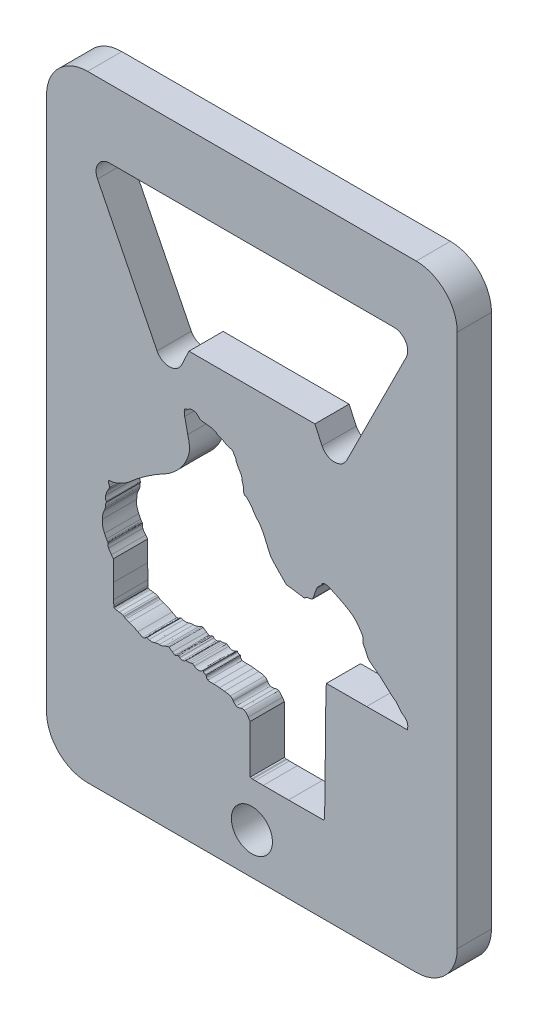
from build123d import *

# Parameters (mm, degrees)
BOSS_EXTRUDE1_DEPTH = 3.175
SKETCH3_R           = 1.905
CUT_EXTRUDE1_DEPTH  = 4.175
CUT_EXTRUDE3_DEPTH  = 4.175


with BuildPart() as part:
    # Sketch1 → Boss-Extrude1 (new body)
    with BuildSketch(Plane.XY):
        with BuildLine():
            Line((40.64, 0), (10.16, 0))
            ThreePointArc((10.16, 0), (7.465923164, 1.115923164), (6.35, 3.81))
            Line((6.35, 3.81), (6.35, 53.34))
            ThreePointArc((6.35, 53.34), (7.465923164, 56.034076836), (10.16, 57.15))
            Line((10.16, 57.15), (40.64, 57.15))
            ThreePointArc((40.64, 57.15), (43.334076836, 56.034076836), (44.45, 53.34))
            Line((44.45, 53.34), (44.45, 3.81))
            ThreePointArc((44.45, 3.81), (43.334076836, 1.115923164), (40.64, 0))
        make_face()
        with BuildLine():
            Line((38.585096834, 50.8), (12.214903166, 50.8))
            ThreePointArc((12.214903166, 50.8), (11.134576639, 50.197678512), (11.078980633, 48.962038734))
            Line((11.078980633, 48.962038734), (16.604643113, 37.910713774))
            ThreePointArc((16.604643113, 37.910713774), (17.757723109, 37.208790943), (18.891418233, 37.9416105))
            Line((18.891418233, 37.9416105), (19.558, 39.37))
            Line((19.558, 39.37), (31.242, 39.37))
            Line((31.242, 39.37), (31.908581767, 37.9416105))
            ThreePointArc((31.908581767, 37.9416105), (33.042276891, 37.208790943), (34.195356887, 37.910713774))
            Line((34.195356887, 37.910713774), (39.721019367, 48.962038734))
            ThreePointArc((39.721019367, 48.962038734), (39.665423361, 50.197678512), (38.585096834, 50.8))
        make_face(mode=Mode.SUBTRACT)
    extrude(amount=BOSS_EXTRUDE1_DEPTH)

    # Sketch3 → Cut-Extrude1 (cut, through all)
    with BuildSketch(Plane.XY.offset(3.175)):
        with Locations((25.4, 3.81)):
            Circle(SKETCH3_R)
    extrude(amount=-CUT_EXTRUDE1_DEPTH, mode=Mode.SUBTRACT)

    # Sketch4 → Cut-Extrude3 (cut, through all)
    with BuildSketch(Plane.XY.offset(3.175)):
        with BuildLine():
            Line((25.059420308, 12.72168685), (25.240760339, 12.460211785))
            Line((25.240760339, 12.460211785), (25.240760339, 10.238510318))
            Line((25.240760339, 10.238510318), (25.240760339, 7.985427565))
            Line((25.240760339, 7.985427565), (25.391840027, 7.948779703))
            add(Edge.make_bspline(
                [(25.391840027, 7.948779703), (25.401896377, 7.946340795), (25.410802303, 7.945881683), (25.426808204, 7.944854678)],
                knots=[0, 0, 0, 0, 1, 1, 1, 1], degree=3))
            add(Edge.make_bspline(
                [(25.426808204, 7.944854678), (25.442814105, 7.94382808), (25.464036361, 7.942967194), (25.490243788, 7.942054866)],
                knots=[0, 0, 0, 0, 1, 1, 1, 1], degree=3))
            add(Edge.make_bspline(
                [(25.490243788, 7.942054866), (25.542658439, 7.940223093), (25.615230725, 7.93847875), (25.705991628, 7.937009713)],
                knots=[0, 0, 0, 0, 1, 1, 1, 1], degree=3))
            add(Edge.make_bspline(
                [(25.705991628, 7.937009713), (25.887513637, 7.934072247), (26.141472517, 7.931908848), (26.449286212, 7.930509958)],
                knots=[0, 0, 0, 0, 1, 1, 1, 1], degree=3))
            add(Edge.make_bspline(
                [(26.449286212, 7.930509958), (27.064919499, 7.927716449), (27.896186357, 7.928169868), (28.794613545, 7.932536722)],
                knots=[0, 0, 0, 0, 1, 1, 1, 1], degree=3))
            Line((28.794613545, 7.932536722), (32.083175645, 7.948449093))
            Line((32.083175645, 7.948449093), (32.129799746, 8.122616968))
            add(Edge.make_bspline(
                [(32.129799746, 8.122616968), (32.133133699, 8.135083353), (32.133540963, 8.146493048), (32.135067542, 8.168568463)],
                knots=[0, 0, 0, 0, 1, 1, 1, 1], degree=3))
            add(Edge.make_bspline(
                [(32.135067542, 8.168568463), (32.136593917, 8.190643269), (32.138085728, 8.220487199), (32.139663952, 8.257781234)],
                knots=[0, 0, 0, 0, 1, 1, 1, 1], degree=3))
            add(Edge.make_bspline(
                [(32.139663952, 8.257781234), (32.1428143, 8.332369914), (32.146166553, 8.436970066), (32.149526938, 8.568346961)],
                knots=[0, 0, 0, 0, 1, 1, 1, 1], degree=3))
            add(Edge.make_bspline(
                [(32.149526938, 8.568346961), (32.156247099, 8.831099326), (32.163293802, 9.200897461), (32.170260599, 9.650786101)],
                knots=[0, 0, 0, 0, 1, 1, 1, 1], degree=3))
            add(Edge.make_bspline(
                [(32.170260599, 9.650786101), (32.184195615, 10.550562364), (32.197803681, 11.770447913), (32.207694726, 13.09345319)],
                knots=[0, 0, 0, 0, 1, 1, 1, 1], degree=3))
            add(Edge.make_bspline(
                [(32.207694726, 13.09345319), (32.217584755, 14.416347654), (32.230245317, 15.685149613), (32.242774937, 16.66355263)],
                knots=[0, 0, 0, 0, 1, 1, 1, 1], degree=3))
            add(Edge.make_bspline(
                [(32.242774937, 16.66355263), (32.255303946, 17.641955038), (32.267789038, 18.332002957), (32.276731562, 18.490518923)],
                knots=[0, 0, 0, 0, 1, 1, 1, 1], degree=3))
            Line((32.276731562, 18.490518923), (32.308337728, 19.051352127))
            Line((32.308337728, 19.051352127), (36.048793882, 19.066034167))
            Line((36.048793882, 19.066034167), (39.842934666, 19.080828239))
            Line((39.842934666, 19.080828239), (39.860418958, 19.337036525))
            add(Edge.make_bspline(
                [(39.860418958, 19.337036525), (39.880872028, 19.637326715), (39.719870796, 19.908036893), (39.410544551, 20.103306247)],
                knots=[0, 0, 0, 0, 1, 1, 1, 1], degree=3))
            add(Edge.make_bspline(
                [(39.410544551, 20.103306247), (39.294622542, 20.176484448), (39.11265972, 20.36999055), (39.01793882, 20.523930642)],
                knots=[0, 0, 0, 0, 1, 1, 1, 1], degree=3))
            add(Edge.make_bspline(
                [(39.01793882, 20.523930642), (38.915230423, 20.690853163), (38.758066582, 20.858887272), (38.640575701, 20.918666427)],
                knots=[0, 0, 0, 0, 1, 1, 1, 1], degree=3))
            add(Edge.make_bspline(
                [(38.640575701, 20.918666427), (38.59685877, 20.940908774), (38.478925653, 21.031353707), (38.336062817, 21.154139222)],
                knots=[0, 0, 0, 0, 1, 1, 1, 1], degree=3))
            add(Edge.make_bspline(
                [(38.336062817, 21.154139222), (38.19319937, 21.276925347), (38.02165055, 21.433513163), (37.856373148, 21.593705764)],
                knots=[0, 0, 0, 0, 1, 1, 1, 1], degree=3))
            add(Edge.make_bspline(
                [(37.856373148, 21.593705764), (37.523759455, 21.916086822), (37.073205529, 22.296095835), (36.847904574, 22.443024805)],
                knots=[0, 0, 0, 0, 1, 1, 1, 1], degree=3))
            add(Edge.make_bspline(
                [(36.847904574, 22.443024805), (36.362019938, 22.759891839), (36.106825034, 23.030346231), (36.059668013, 23.255133583)],
                knots=[0, 0, 0, 0, 1, 1, 1, 1], degree=3))
            add(Edge.make_bspline(
                [(36.059668013, 23.255133583), (36.036862653, 23.363840127), (35.940892919, 23.566534983), (35.842910655, 23.721038087)],
                knots=[0, 0, 0, 0, 1, 1, 1, 1], degree=3))
            add(Edge.make_bspline(
                [(35.842910655, 23.721038087), (35.770134838, 23.835792186), (35.729311046, 23.912354764), (35.709875425, 23.982289696)],
                knots=[0, 0, 0, 0, 1, 1, 1, 1], degree=3))
            add(Edge.make_bspline(
                [(35.709875425, 23.982289696), (35.6904396, 24.052224018), (35.691016236, 24.117548103), (35.704383766, 24.215073492)],
                knots=[0, 0, 0, 0, 1, 1, 1, 1], degree=3))
            add(Edge.make_bspline(
                [(35.704383766, 24.215073492), (35.719190445, 24.323100517), (35.719703439, 24.40230472), (35.681968591, 24.504119495)],
                knots=[0, 0, 0, 0, 1, 1, 1, 1], degree=3))
            add(Edge.make_bspline(
                [(35.681968591, 24.504119495), (35.644233336, 24.605934677), (35.57059948, 24.730168084), (35.438201071, 24.941443543)],
                knots=[0, 0, 0, 0, 1, 1, 1, 1], degree=3))
            add(Edge.make_bspline(
                [(35.438201071, 24.941443543), (35.02973685, 25.59325399), (34.602306898, 25.925205447), (33.426641514, 26.505702812)],
                knots=[0, 0, 0, 0, 1, 1, 1, 1], degree=3))
            add(Edge.make_bspline(
                [(33.426641514, 26.505702812), (32.691182543, 26.868843411), (32.433813463, 26.970933491), (32.228986926, 26.970933491)],
                knots=[0, 0, 0, 0, 1, 1, 1, 1], degree=3))
            add(Edge.make_bspline(
                [(32.228986926, 26.970933491), (32.123207478, 26.970933491), (32.056047553, 26.96658392), (32.004609075, 26.94302686)],
                knots=[0, 0, 0, 0, 1, 1, 1, 1], degree=3))
            add(Edge.make_bspline(
                [(32.004609075, 26.94302686), (31.953170191, 26.919468784), (31.924363025, 26.875427546), (31.901273821, 26.814699261)],
                knots=[0, 0, 0, 0, 1, 1, 1, 1], degree=3))
            add(Edge.make_bspline(
                [(31.901273821, 26.814699261), (31.889353572, 26.783344407), (31.855332492, 26.732458572), (31.811052141, 26.681438948)],
                knots=[0, 0, 0, 0, 1, 1, 1, 1], degree=3))
            add(Edge.make_bspline(
                [(31.811052141, 26.681438948), (31.766771587, 26.630419934), (31.712161615, 26.577990441), (31.659411881, 26.537756094)],
                knots=[0, 0, 0, 0, 1, 1, 1, 1], degree=3))
            add(Edge.make_bspline(
                [(31.659411881, 26.537756094), (31.560492685, 26.462307137), (31.496088452, 26.397515565), (31.419118812, 26.232010437)],
                knots=[0, 0, 0, 0, 1, 1, 1, 1], degree=3))
            add(Edge.make_bspline(
                [(31.419118812, 26.232010437), (31.342149377, 26.066506326), (31.249330601, 25.798758216), (31.082552036, 25.304685602)],
                knots=[0, 0, 0, 0, 1, 1, 1, 1], degree=3))
            add(Edge.make_bspline(
                [(31.082552036, 25.304685602), (31.054624056, 25.221950219), (31.03663165, 25.184712302), (30.994459393, 25.159433876)],
                knots=[0, 0, 0, 0, 1, 1, 1, 1], degree=3))
            add(Edge.make_bspline(
                [(30.994459393, 25.159433876), (30.952287137, 25.134155857), (30.87642868, 25.119622247), (30.735785971, 25.102050931)],
                knots=[0, 0, 0, 0, 1, 1, 1, 1], degree=3))
            add(Edge.make_bspline(
                [(30.735785971, 25.102050931), (30.528016682, 25.076091359), (30.391868313, 25.029262914), (30.332084482, 24.943910306)],
                knots=[0, 0, 0, 0, 1, 1, 1, 1], degree=3))
            add(Edge.make_bspline(
                [(30.332084482, 24.943910306), (30.312716975, 24.916259054), (30.29190178, 24.894243213), (30.276606303, 24.882604166)],
                knots=[0, 0, 0, 0, 1, 1, 1, 1], degree=3))
            add(Edge.make_bspline(
                [(30.276606303, 24.882604166), (30.26965435, 24.877313394), (30.26462404, 24.875039995), (30.262372803, 24.874197611)],
                knots=[0, 0, 0, 0, 1, 1, 1, 1], degree=3))
            add(Edge.make_bspline(
                [(30.262372803, 24.874197611), (30.260037389, 24.875109939), (30.256530202, 24.87807099), (30.254191128, 24.878903005)],
                knots=[0, 0, 0, 0, 1, 1, 1, 1], degree=3))
            add(Edge.make_bspline(
                [(30.254191128, 24.878903005), (30.249101243, 24.880716275), (30.243391618, 24.882351837), (30.236483176, 24.8841708)],
                knots=[0, 0, 0, 0, 1, 1, 1, 1], degree=3))
            add(Edge.make_bspline(
                [(30.236483176, 24.8841708), (30.222665887, 24.887803237), (30.204273333, 24.891934232), (30.181341301, 24.896610956)],
                knots=[0, 0, 0, 0, 1, 1, 1, 1], degree=3))
            add(Edge.make_bspline(
                [(30.181341301, 24.896610956), (30.135477033, 24.905965015), (30.071667124, 24.917448111), (29.994172697, 24.930458599)],
                knots=[0, 0, 0, 0, 1, 1, 1, 1], degree=3))
            add(Edge.make_bspline(
                [(29.994172697, 24.930458599), (29.839183438, 24.956480795), (29.629578107, 24.988439936), (29.40263305, 25.020008283)],
                knots=[0, 0, 0, 0, 1, 1, 1, 1], degree=3))
            Line((29.40263305, 25.020008283), (28.587945476, 25.133318557))
            Line((28.587945476, 25.133318557), (27.874800016, 25.857896484))
            add(Edge.make_bspline(
                [(27.874800016, 25.857896484), (27.277236399, 26.4650978), (27.136174226, 26.642236283), (27.023349294, 26.924307153)],
                knots=[0, 0, 0, 0, 1, 1, 1, 1], degree=3))
            add(Edge.make_bspline(
                [(27.023349294, 26.924307153), (26.586831438, 28.01563514), (26.257460404, 28.655407612), (25.977110493, 28.942029144)],
                knots=[0, 0, 0, 0, 1, 1, 1, 1], degree=3))
            add(Edge.make_bspline(
                [(25.977110493, 28.942029144), (25.825280935, 29.097255279), (25.625395448, 29.361548863), (25.538105134, 29.521579209)],
                knots=[0, 0, 0, 0, 1, 1, 1, 1], degree=3))
            add(Edge.make_bspline(
                [(25.538105134, 29.521579209), (25.454179475, 29.675440613), (25.301604521, 29.88077506), (25.157380003, 30.049349613)],
                knots=[0, 0, 0, 0, 1, 1, 1, 1], degree=3))
            add(Edge.make_bspline(
                [(25.157380003, 30.049349613), (25.085267439, 30.133635567), (25.015355483, 30.208523748), (24.956761929, 30.263079432)],
                knots=[0, 0, 0, 0, 1, 1, 1, 1], degree=3))
            add(Edge.make_bspline(
                [(24.956761929, 30.263079432), (24.927465354, 30.290357782), (24.901112549, 30.312575324), (24.877859666, 30.32864446)],
                knots=[0, 0, 0, 0, 1, 1, 1, 1], degree=3))
            add(Edge.make_bspline(
                [(24.877859666, 30.32864446), (24.854606784, 30.344714206), (24.836366929, 30.356551701), (24.811398373, 30.356551701)],
                knots=[0, 0, 0, 0, 1, 1, 1, 1], degree=3))
            add(Edge.make_bspline(
                [(24.811398373, 30.356551701), (24.753051454, 30.356551701), (24.705869017, 30.394470153), (24.668724224, 30.477818973)],
                knots=[0, 0, 0, 0, 1, 1, 1, 1], degree=3))
            add(Edge.make_bspline(
                [(24.668724224, 30.477818973), (24.631579837, 30.561168404), (24.609547527, 30.687303325), (24.609547527, 30.84509504)],
                knots=[0, 0, 0, 0, 1, 1, 1, 1], degree=3))
            add(Edge.make_bspline(
                [(24.609547527, 30.84509504), (24.609547527, 30.939053463), (24.603101655, 31.028287584), (24.592399741, 31.097716841)],
                knots=[0, 0, 0, 0, 1, 1, 1, 1], degree=3))
            add(Edge.make_bspline(
                [(24.592399741, 31.097716841), (24.587051631, 31.13243208), (24.580725112, 31.162153201), (24.573122918, 31.185809484)],
                knots=[0, 0, 0, 0, 1, 1, 1, 1], degree=3))
            add(Edge.make_bspline(
                [(24.573122918, 31.185809484), (24.565520115, 31.20946536), (24.560628881, 31.228123459), (24.53860267, 31.241735388)],
                knots=[0, 0, 0, 0, 1, 1, 1, 1], degree=3))
            add(Edge.make_bspline(
                [(24.53860267, 31.241735388), (24.541052964, 31.240220399), (24.533558737, 31.247238434), (24.527731386, 31.261460954)],
                knots=[0, 0, 0, 0, 1, 1, 1, 1], degree=3))
            add(Edge.make_bspline(
                [(24.527731386, 31.261460954), (24.521905864, 31.275685711), (24.516097015, 31.296203642), (24.511144172, 31.320526228)],
                knots=[0, 0, 0, 0, 1, 1, 1, 1], degree=3))
            add(Edge.make_bspline(
                [(24.511144172, 31.320526228), (24.501238081, 31.369171399), (24.494780822, 31.433258239), (24.494780822, 31.499176243)],
                knots=[0, 0, 0, 0, 1, 1, 1, 1], degree=3))
            add(Edge.make_bspline(
                [(24.494780822, 31.499176243), (24.494780822, 31.700066369), (24.437416379, 31.841360334), (24.230279437, 32.156731491)],
                knots=[0, 0, 0, 0, 1, 1, 1, 1], degree=3))
            add(Edge.make_bspline(
                [(24.230279437, 32.156731491), (24.159653804, 32.264261585), (24.091304823, 32.386663829), (24.038515644, 32.49643723)],
                knots=[0, 0, 0, 0, 1, 1, 1, 1], degree=3))
            add(Edge.make_bspline(
                [(24.038515644, 32.49643723), (23.985726262, 32.606210427), (23.948663613, 32.705022469), (23.940224119, 32.757800669)],
                knots=[0, 0, 0, 0, 1, 1, 1, 1], degree=3))
            add(Edge.make_bspline(
                [(23.940224119, 32.757800669), (23.93043799, 32.818999046), (23.915806376, 32.877963876), (23.899652453, 32.924906997)],
                knots=[0, 0, 0, 0, 1, 1, 1, 1], degree=3))
            add(Edge.make_bspline(
                [(23.899652453, 32.924906997), (23.891575084, 32.948379066), (23.883196589, 32.968915906), (23.874322788, 32.985653581)],
                knots=[0, 0, 0, 0, 1, 1, 1, 1], degree=3))
            add(Edge.make_bspline(
                [(23.874322788, 32.985653581), (23.865449598, 33.002390037), (23.857845778, 33.015846421), (23.841596494, 33.025888538)],
                knots=[0, 0, 0, 0, 1, 1, 1, 1], degree=3))
            add(Edge.make_bspline(
                [(23.841596494, 33.025888538), (23.841137382, 33.026175432), (23.832568979, 33.03374489), (23.82355224, 33.045614104)],
                knots=[0, 0, 0, 0, 1, 1, 1, 1], degree=3))
            add(Edge.make_bspline(
                [(23.82355224, 33.045614104), (23.814535094, 33.057483927), (23.803823218, 33.073631548), (23.79261868, 33.092574914)],
                knots=[0, 0, 0, 0, 1, 1, 1, 1], degree=3))
            add(Edge.make_bspline(
                [(23.79261868, 33.092574914), (23.770209198, 33.130460021), (23.745577962, 33.17938558), (23.724812175, 33.229083782)],
                knots=[0, 0, 0, 0, 1, 1, 1, 1], degree=3))
            add(Edge.make_bspline(
                [(23.724812175, 33.229083782), (23.691328285, 33.309222476), (23.657018684, 33.364886089), (23.598501376, 33.405156628)],
                knots=[0, 0, 0, 0, 1, 1, 1, 1], degree=3))
            add(Edge.make_bspline(
                [(23.598501376, 33.405156628), (23.539984679, 33.445427777), (23.461561048, 33.469512673), (23.338819248, 33.497845071)],
                knots=[0, 0, 0, 0, 1, 1, 1, 1], degree=3))
            add(Edge.make_bspline(
                [(23.338819248, 33.497845071), (23.184869804, 33.533380937), (22.958754117, 33.628882409), (22.847137557, 33.7046268)],
                knots=[0, 0, 0, 0, 1, 1, 1, 1], degree=3))
            add(Edge.make_bspline(
                [(22.847137557, 33.7046268), (22.726184221, 33.78670747), (22.544752896, 33.86824119), (22.430547983, 33.889665349)],
                knots=[0, 0, 0, 0, 1, 1, 1, 1], degree=3))
            add(Edge.make_bspline(
                [(22.430547983, 33.889665349), (22.380190595, 33.899112328), (22.325913876, 33.916972979), (22.280476594, 33.937746288)],
                knots=[0, 0, 0, 0, 1, 1, 1, 1], degree=3))
            add(Edge.make_bspline(
                [(22.280476594, 33.937746288), (22.235039719, 33.958520208), (22.198150305, 33.983706933), (22.184762849, 33.999837474)],
                knots=[0, 0, 0, 0, 1, 1, 1, 1], degree=3))
            add(Edge.make_bspline(
                [(22.184762849, 33.999837474), (22.028433665, 34.188202454), (21.734167038, 34.27608628), (21.179545067, 34.314549242)],
                knots=[0, 0, 0, 0, 1, 1, 1, 1], degree=3))
            add(Edge.make_bspline(
                [(21.179545067, 34.314549242), (20.9209973, 34.332479226), (20.77770341, 34.345877662), (20.689207976, 34.370363723)],
                knots=[0, 0, 0, 0, 1, 1, 1, 1], degree=3))
            add(Edge.make_bspline(
                [(20.689207976, 34.370363723), (20.60071234, 34.394849784), (20.566102831, 34.426939664), (20.510109218, 34.494993008)],
                knots=[0, 0, 0, 0, 1, 1, 1, 1], degree=3))
            add(Edge.make_bspline(
                [(20.510109218, 34.494993008), (20.437664418, 34.583042138), (20.30449296, 34.691543119), (20.204362952, 34.744028934)],
                knots=[0, 0, 0, 0, 1, 1, 1, 1], degree=3))
            add(Edge.make_bspline(
                [(20.204362952, 34.744028934), (20.098797607, 34.799363157), (19.966695852, 34.818925248), (19.84089764, 34.808248954)],
                knots=[0, 0, 0, 0, 1, 1, 1, 1], degree=3))
            add(Edge.make_bspline(
                [(19.84089764, 34.808248954), (19.715099429, 34.797571643), (19.595078754, 34.756862121), (19.514641576, 34.684066785)],
                knots=[0, 0, 0, 0, 1, 1, 1, 1], degree=3))
            add(Edge.make_bspline(
                [(19.514641576, 34.684066785), (19.490363112, 34.662095879), (19.457860071, 34.641135916), (19.4264369, 34.626235706)],
                knots=[0, 0, 0, 0, 1, 1, 1, 1], degree=3))
            add(Edge.make_bspline(
                [(19.4264369, 34.626235706), (19.395014339, 34.611336107), (19.363845326, 34.602923249), (19.347198538, 34.602923249)],
                knots=[0, 0, 0, 0, 1, 1, 1, 1], degree=3))
            add(Edge.make_bspline(
                [(19.347198538, 34.602923249), (19.282555598, 34.602923249), (19.20866982, 34.559373859), (19.161935719, 34.503062853)],
                knots=[0, 0, 0, 0, 1, 1, 1, 1], degree=3))
            add(Edge.make_bspline(
                [(19.161935719, 34.503062853), (19.129260867, 34.463692646), (19.12378893, 34.400692588), (19.125625176, 34.306143703)],
                knots=[0, 0, 0, 0, 1, 1, 1, 1], degree=3))
            add(Edge.make_bspline(
                [(19.125625176, 34.306143703), (19.127461423, 34.211594208), (19.141050376, 34.085809823), (19.166084403, 33.928780178)],
                knots=[0, 0, 0, 0, 1, 1, 1, 1], degree=3))
            add(Edge.make_bspline(
                [(19.166084403, 33.928780178), (19.216153677, 33.614720887), (19.312058143, 33.175848504), (19.452441407, 32.619721913)],
                knots=[0, 0, 0, 0, 1, 1, 1, 1], degree=3))
            add(Edge.make_bspline(
                [(19.452441407, 32.619721913), (19.723827037, 31.544633044), (19.66400254, 31.058863085), (19.146023144, 30.132622186)],
                knots=[0, 0, 0, 0, 1, 1, 1, 1], degree=3))
            add(Edge.make_bspline(
                [(19.146023144, 30.132622186), (18.770571706, 29.461249648), (17.997909383, 28.737094641), (17.25158604, 28.358332632)],
                knots=[0, 0, 0, 0, 1, 1, 1, 1], degree=3))
            add(Edge.make_bspline(
                [(17.25158604, 28.358332632), (16.320494572, 27.885798244), (14.768006716, 26.803572597), (14.08855071, 26.152881669)],
                knots=[0, 0, 0, 0, 1, 1, 1, 1], degree=3))
            add(Edge.make_bspline(
                [(14.08855071, 26.152881669), (13.900106434, 25.972415943), (13.560187812, 25.758975052), (13.224214953, 25.592497207)],
                knots=[0, 0, 0, 0, 1, 1, 1, 1], degree=3))
            add(Edge.make_bspline(
                [(13.224214953, 25.592497207), (12.888240265, 25.426018753), (12.551669422, 25.306812809), (12.384870931, 25.306812809)],
                knots=[0, 0, 0, 0, 1, 1, 1, 1], degree=3))
            add(Edge.make_bspline(
                [(12.384870931, 25.306812809), (12.31319613, 25.306812809), (12.257098617, 25.304127266), (12.212384367, 25.293587608)],
                knots=[0, 0, 0, 0, 1, 1, 1, 1], degree=3))
            add(Edge.make_bspline(
                [(12.212384367, 25.293587608), (12.167669506, 25.283048559), (12.131733696, 25.262374473), (12.11342044, 25.227238551)],
                knots=[0, 0, 0, 0, 1, 1, 1, 1], degree=3))
            add(Edge.make_bspline(
                [(12.11342044, 25.227238551), (12.095106573, 25.192101612), (12.095459956, 25.14937285), (12.105574864, 25.096780898)],
                knots=[0, 0, 0, 0, 1, 1, 1, 1], degree=3))
            add(Edge.make_bspline(
                [(12.105574864, 25.096780898), (12.115689975, 25.044188946), (12.136320346, 24.980098039), (12.165535996, 24.899301583)],
                knots=[0, 0, 0, 0, 1, 1, 1, 1], degree=3))
            add(Edge.make_bspline(
                [(12.165535996, 24.899301583), (12.193427784, 24.822170298), (12.202561436, 24.778898653), (12.187391005, 24.719642252)],
                knots=[0, 0, 0, 0, 1, 1, 1, 1], degree=3))
            add(Edge.make_bspline(
                [(12.187391005, 24.719642252), (12.172220575, 24.660385241), (12.129147986, 24.582337562), (12.046734673, 24.449760632)],
                knots=[0, 0, 0, 0, 1, 1, 1, 1], degree=3))
            add(Edge.make_bspline(
                [(12.046734673, 24.449760632), (11.942767885, 24.282515634), (11.86953011, 24.088491455), (11.836254629, 23.917170971)],
                knots=[0, 0, 0, 0, 1, 1, 1, 1], degree=3))
            add(Edge.make_bspline(
                [(11.836254629, 23.917170971), (11.802977929, 23.745850081), (11.805066708, 23.596490743), (11.873687537, 23.513805989)],
                knots=[0, 0, 0, 0, 1, 1, 1, 1], degree=3))
            add(Edge.make_bspline(
                [(11.873687537, 23.513805989), (11.897647997, 23.484929488), (11.906711705, 23.464339173), (11.906972777, 23.440059082)],
                knots=[0, 0, 0, 0, 1, 1, 1, 1], degree=3))
            add(Edge.make_bspline(
                [(11.906972777, 23.440059082), (11.907259671, 23.415778992), (11.897089661, 23.384128095), (11.872677612, 23.338517985)],
                knots=[0, 0, 0, 0, 1, 1, 1, 1], degree=3))
            add(Edge.make_bspline(
                [(11.872677612, 23.338517985), (11.831794245, 23.262101599), (11.814366885, 23.152672634), (11.834347626, 23.076258078)],
                knots=[0, 0, 0, 0, 1, 1, 1, 1], degree=3))
            add(Edge.make_bspline(
                [(11.834347626, 23.076258078), (11.839799229, 23.055355655), (11.834347626, 22.995252194), (11.813391322, 22.924169685)],
                knots=[0, 0, 0, 0, 1, 1, 1, 1], degree=3))
            add(Edge.make_bspline(
                [(11.813391322, 22.924169685), (11.79257267, 22.853086566), (11.758733567, 22.768659502), (11.716441958, 22.686453786)],
                knots=[0, 0, 0, 0, 1, 1, 1, 1], degree=3))
            add(Edge.make_bspline(
                [(11.716441958, 22.686453786), (11.594060453, 22.448582952), (11.55778834, 22.280105997), (11.538014179, 21.86134367)],
                knots=[0, 0, 0, 0, 1, 1, 1, 1], degree=3))
            add(Edge.make_bspline(
                [(11.538014179, 21.86134367), (11.514383719, 21.360915665), (11.524006779, 21.30907033), (11.732021686, 20.824856025)],
                knots=[0, 0, 0, 0, 1, 1, 1, 1], degree=3))
            add(Edge.make_bspline(
                [(11.732021686, 20.824856025), (11.791826663, 20.685638232), (11.854563819, 20.555894867), (11.907869652, 20.458363784)],
                knots=[0, 0, 0, 0, 1, 1, 1, 1], degree=3))
            add(Edge.make_bspline(
                [(11.907869652, 20.458363784), (11.934522569, 20.409598853), (11.958799609, 20.368974119), (11.979598945, 20.338666603)],
                knots=[0, 0, 0, 0, 1, 1, 1, 1], degree=3))
            add(Edge.make_bspline(
                [(11.979598945, 20.338666603), (11.989997901, 20.323511625), (11.999454029, 20.310963706), (12.008514281, 20.300896376)],
                knots=[0, 0, 0, 0, 1, 1, 1, 1], degree=3))
            add(Edge.make_bspline(
                [(12.008514281, 20.300896376), (12.017575142, 20.290827826), (12.024892677, 20.282660384), (12.038999301, 20.277247413)],
                knots=[0, 0, 0, 0, 1, 1, 1, 1], degree=3))
            add(Edge.make_bspline(
                [(12.038999301, 20.277247413), (12.053101858, 20.271836271), (12.062421555, 20.261067057), (12.06825155, 20.235218705)],
                knots=[0, 0, 0, 0, 1, 1, 1, 1], degree=3))
            add(Edge.make_bspline(
                [(12.06825155, 20.235218705), (12.074081748, 20.209370354), (12.073467701, 20.170179278), (12.06365514, 20.121124402)],
                knots=[0, 0, 0, 0, 1, 1, 1, 1], degree=3))
            add(Edge.make_bspline(
                [(12.06365514, 20.121124402), (12.04427218, 20.024216517), (12.053140287, 19.931872307), (12.10142496, 19.824793193)],
                knots=[0, 0, 0, 0, 1, 1, 1, 1], degree=3))
            add(Edge.make_bspline(
                [(12.10142496, 19.824793193), (12.149709632, 19.717713875), (12.235980465, 19.594626012), (12.372202845, 19.426022587)],
                knots=[0, 0, 0, 0, 1, 1, 1, 1], degree=3))
            Line((12.372202845, 19.426022587), (12.559035146, 19.194807662))
            Line((12.559035146, 19.194807662), (12.559930395, 17.292188883))
            add(Edge.make_bspline(
                [(12.559930395, 17.292188883), (12.560159951, 16.766019882), (12.565462109, 16.279861975), (12.573715559, 15.920144997)],
                knots=[0, 0, 0, 0, 1, 1, 1, 1], degree=3))
            add(Edge.make_bspline(
                [(12.573715559, 15.920144997), (12.57784147, 15.740286406), (12.582659913, 15.592076069), (12.588061498, 15.486071131)],
                knots=[0, 0, 0, 0, 1, 1, 1, 1], degree=3))
            add(Edge.make_bspline(
                [(12.588061498, 15.486071131), (12.590764121, 15.433068458), (12.593593213, 15.390580638), (12.596579476, 15.359648095)],
                knots=[0, 0, 0, 0, 1, 1, 1, 1], degree=3))
            add(Edge.make_bspline(
                [(12.596579476, 15.359648095), (12.59807149, 15.344181417), (12.599597866, 15.331702832), (12.60128487, 15.321654005)],
                knots=[0, 0, 0, 0, 1, 1, 1, 1], degree=3))
            add(Edge.make_bspline(
                [(12.60128487, 15.321654005), (12.602971874, 15.311604975), (12.601921893, 15.306556366), (12.609914678, 15.293971034)],
                knots=[0, 0, 0, 0, 1, 1, 1, 1], degree=3))
            add(Edge.make_bspline(
                [(12.609914678, 15.293971034), (12.624384037, 15.271200647), (12.645333021, 15.263420136), (12.673798598, 15.25227802)],
                knots=[0, 0, 0, 0, 1, 1, 1, 1], degree=3))
            add(Edge.make_bspline(
                [(12.673798598, 15.25227802), (12.702264785, 15.24113692), (12.738662961, 15.230522234), (12.781280503, 15.220448601)],
                knots=[0, 0, 0, 0, 1, 1, 1, 1], degree=3))
            add(Edge.make_bspline(
                [(12.781280503, 15.220448601), (12.866515588, 15.200301742), (12.976530338, 15.182556581), (13.092182126, 15.171807496)],
                knots=[0, 0, 0, 0, 1, 1, 1, 1], degree=3))
            add(Edge.make_bspline(
                [(13.092182126, 15.171807496), (13.246718982, 15.157444477), (13.353022201, 15.141417836), (13.423032974, 15.120700645)],
                knots=[0, 0, 0, 0, 1, 1, 1, 1], degree=3))
            add(Edge.make_bspline(
                [(13.423032974, 15.120700645), (13.493043543, 15.099982437), (13.524024885, 15.076520128), (13.53936916, 15.047850207)],
                knots=[0, 0, 0, 0, 1, 1, 1, 1], degree=3))
            add(Edge.make_bspline(
                [(13.53936916, 15.047850207), (13.551619408, 15.024959857), (13.572763383, 15.00761525), (13.601459736, 14.988112938)],
                knots=[0, 0, 0, 0, 1, 1, 1, 1], degree=3))
            add(Edge.make_bspline(
                [(13.601459736, 14.988112938), (13.630156089, 14.968610625), (13.666698221, 14.948391585), (13.709613637, 14.927703673)],
                knots=[0, 0, 0, 0, 1, 1, 1, 1], degree=3))
            add(Edge.make_bspline(
                [(13.709613637, 14.927703673), (13.795444877, 14.886328458), (13.906677962, 14.843595223), (14.027239894, 14.806997176)],
                knots=[0, 0, 0, 0, 1, 1, 1, 1], degree=3))
            add(Edge.make_bspline(
                [(14.027239894, 14.806997176), (14.253167503, 14.738412539), (14.613729712, 14.580515704), (14.821305026, 14.459334642)],
                knots=[0, 0, 0, 0, 1, 1, 1, 1], degree=3))
            add(Edge.make_bspline(
                [(14.821305026, 14.459334642), (15.034269116, 14.335006078), (15.168673753, 14.266310018), (15.276113163, 14.246275802)],
                knots=[0, 0, 0, 0, 1, 1, 1, 1], degree=3))
            add(Edge.make_bspline(
                [(15.276113163, 14.246275802), (15.383553386, 14.226241586), (15.463334021, 14.261803275), (15.54364107, 14.334480478)],
                knots=[0, 0, 0, 0, 1, 1, 1, 1], degree=3))
            add(Edge.make_bspline(
                [(15.54364107, 14.334480478), (15.588813213, 14.375360388), (15.613428386, 14.391186751), (15.652916116, 14.393208432)],
                knots=[0, 0, 0, 0, 1, 1, 1, 1], degree=3))
            add(Edge.make_bspline(
                [(15.652916116, 14.393208432), (15.692404049, 14.395228282), (15.752405237, 14.380138165), (15.85611136, 14.345911725)],
                knots=[0, 0, 0, 0, 1, 1, 1, 1], degree=3))
            add(Edge.make_bspline(
                [(15.85611136, 14.345911725), (16.062300798, 14.277864278), (16.143938418, 14.280037437), (16.376372695, 14.360257665)],
                knots=[0, 0, 0, 0, 1, 1, 1, 1], degree=3))
            add(Edge.make_bspline(
                [(16.376372695, 14.360257665), (16.518459839, 14.409297494), (16.71896649, 14.436488617), (16.803498064, 14.422909423)],
                knots=[0, 0, 0, 0, 1, 1, 1, 1], degree=3))
            add(Edge.make_bspline(
                [(16.803498064, 14.422909423), (16.931993205, 14.402267463), (17.102064447, 14.447757609), (17.329139228, 14.55527225)],
                knots=[0, 0, 0, 0, 1, 1, 1, 1], degree=3))
            add(Edge.make_bspline(
                [(17.329139228, 14.55527225), (17.440160446, 14.60783777), (17.52875246, 14.642362491), (17.593864882, 14.659055231)],
                knots=[0, 0, 0, 0, 1, 1, 1, 1], degree=3))
            add(Edge.make_bspline(
                [(17.593864882, 14.659055231), (17.658977304, 14.675747564), (17.698541891, 14.671396163), (17.710873064, 14.662865579)],
                knots=[0, 0, 0, 0, 1, 1, 1, 1], degree=3))
            add(Edge.make_bspline(
                [(17.710873064, 14.662865579), (17.752388777, 14.63414747), (17.893809009, 14.534182157), (18.02412779, 14.441401811)],
                knots=[0, 0, 0, 0, 1, 1, 1, 1], degree=3))
            add(Edge.make_bspline(
                [(18.02412779, 14.441401811), (18.124317576, 14.370071446), (18.188942216, 14.328902811), (18.246264774, 14.312289166)],
                knots=[0, 0, 0, 0, 1, 1, 1, 1], degree=3))
            add(Edge.make_bspline(
                [(18.246264774, 14.312289166), (18.303586722, 14.29567491), (18.353312983, 14.309368373), (18.402499614, 14.340083966)],
                knots=[0, 0, 0, 0, 1, 1, 1, 1], degree=3))
            add(Edge.make_bspline(
                [(18.402499614, 14.340083966), (18.473008944, 14.384117072), (18.531230614, 14.402633655), (18.578796933, 14.400156929)],
                knots=[0, 0, 0, 0, 1, 1, 1, 1], degree=3))
            add(Edge.make_bspline(
                [(18.578796933, 14.400156929), (18.626363251, 14.397677966), (18.666175694, 14.375900424), (18.705668101, 14.328315196)],
                knots=[0, 0, 0, 0, 1, 1, 1, 1], degree=3))
            add(Edge.make_bspline(
                [(18.705668101, 14.328315196), (18.759751456, 14.263148893), (18.858242038, 14.235883149), (18.955151143, 14.234619065)],
                knots=[0, 0, 0, 0, 1, 1, 1, 1], degree=3))
            add(Edge.make_bspline(
                [(18.955151143, 14.234619065), (19.052060858, 14.233356607), (19.150438187, 14.257883334), (19.203961986, 14.322376015)],
                knots=[0, 0, 0, 0, 1, 1, 1, 1], degree=3))
            add(Edge.make_bspline(
                [(19.203961986, 14.322376015), (19.231091705, 14.35506449), (19.301675046, 14.377336116), (19.346411866, 14.36563668)],
                knots=[0, 0, 0, 0, 1, 1, 1, 1], degree=3))
            add(Edge.make_bspline(
                [(19.346411866, 14.36563668), (19.383287454, 14.355992881), (19.434750128, 14.357013176), (19.495249873, 14.363169307)],
                knots=[0, 0, 0, 0, 1, 1, 1, 1], degree=3))
            add(Edge.make_bspline(
                [(19.495249873, 14.363169307), (19.555750432, 14.369327066), (19.623670596, 14.381547425), (19.685780692, 14.398697041)],
                knots=[0, 0, 0, 0, 1, 1, 1, 1], degree=3))
            add(Edge.make_bspline(
                [(19.685780692, 14.398697041), (19.782904916, 14.425514652), (19.837773724, 14.435218636), (19.886286733, 14.425484153)],
                knots=[0, 0, 0, 0, 1, 1, 1, 1], degree=3))
            add(Edge.make_bspline(
                [(19.886286733, 14.425484153), (19.934799335, 14.41574967), (19.983612455, 14.385145296), (20.066058097, 14.322260728)],
                knots=[0, 0, 0, 0, 1, 1, 1, 1], degree=3))
            add(Edge.make_bspline(
                [(20.066058097, 14.322260728), (20.298310599, 14.145114113), (20.563317861, 14.13311355), (20.768444102, 14.294465927)],
                knots=[0, 0, 0, 0, 1, 1, 1, 1], degree=3))
            add(Edge.make_bspline(
                [(20.768444102, 14.294465927), (20.804527324, 14.32284936), (20.831468355, 14.34402729), (20.850820816, 14.357229516)],
                knots=[0, 0, 0, 0, 1, 1, 1, 1], degree=3))
            add(Edge.make_bspline(
                [(20.850820816, 14.357229516), (20.868303278, 14.369154441), (20.877053659, 14.371310927), (20.878055654, 14.371911148)],
                knots=[0, 0, 0, 0, 1, 1, 1, 1], degree=3))
            add(Edge.make_bspline(
                [(20.878055654, 14.371911148), (20.878732733, 14.370860964), (20.878572105, 14.371256842), (20.879622085, 14.368996049)],
                knots=[0, 0, 0, 0, 1, 1, 1, 1], degree=3))
            add(Edge.make_bspline(
                [(20.879622085, 14.368996049), (20.884189826, 14.358978535), (20.890023481, 14.338189162), (20.897442477, 14.309819352)],
                knots=[0, 0, 0, 0, 1, 1, 1, 1], degree=3))
            add(Edge.make_bspline(
                [(20.897442477, 14.309819352), (20.91842074, 14.229595058), (20.991219126, 14.174430206), (21.075084397, 14.174430206)],
                knots=[0, 0, 0, 0, 1, 1, 1, 1], degree=3))
            add(Edge.make_bspline(
                [(21.075084397, 14.174430206), (21.115936655, 14.174430206), (21.135203718, 14.16702829), (21.146813486, 14.153360039)],
                knots=[0, 0, 0, 0, 1, 1, 1, 1], degree=3))
            add(Edge.make_bspline(
                [(21.146813486, 14.153360039), (21.158423864, 14.139691382), (21.166539052, 14.111537912), (21.166539052, 14.061680912)],
                knots=[0, 0, 0, 0, 1, 1, 1, 1], degree=3))
            add(Edge.make_bspline(
                [(21.166539052, 14.061680912), (21.166539052, 13.953245809), (21.220699875, 13.870155824), (21.328042501, 13.825983237)],
                knots=[0, 0, 0, 0, 1, 1, 1, 1], degree=3))
            add(Edge.make_bspline(
                [(21.328042501, 13.825983237), (21.435384314, 13.781810039), (21.5936937, 13.768773729), (21.818602641, 13.777005422)],
                knots=[0, 0, 0, 0, 1, 1, 1, 1], degree=3))
            add(Edge.make_bspline(
                [(21.818602641, 13.777005422), (22.026686476, 13.784621238), (22.290878397, 13.771542432), (22.39456622, 13.750219327)],
                knots=[0, 0, 0, 0, 1, 1, 1, 1], degree=3))
            add(Edge.make_bspline(
                [(22.39456622, 13.750219327), (22.507696957, 13.726954448), (22.713826209, 13.700995893), (22.857556032, 13.691715235)],
                knots=[0, 0, 0, 0, 1, 1, 1, 1], degree=3))
            add(Edge.make_bspline(
                [(22.857556032, 13.691715235), (23.100116807, 13.676052957), (23.273866845, 13.644433575), (23.400120712, 13.589612956)],
                knots=[0, 0, 0, 0, 1, 1, 1, 1], degree=3))
            add(Edge.make_bspline(
                [(23.400120712, 13.589612956), (23.52637458, 13.534792337), (23.605960631, 13.458354804), (23.666079545, 13.345621572)],
                knots=[0, 0, 0, 0, 1, 1, 1, 1], degree=3))
            add(Edge.make_bspline(
                [(23.666079545, 13.345621572), (23.741830239, 13.20357367), (23.833410143, 13.109461938), (23.948961283, 13.066549572)],
                knots=[0, 0, 0, 0, 1, 1, 1, 1], degree=3))
            add(Edge.make_bspline(
                [(23.948961283, 13.066549572), (24.064513237, 13.023637612), (24.200267356, 13.032798306), (24.361965186, 13.086163714)],
                knots=[0, 0, 0, 0, 1, 1, 1, 1], degree=3))
            add(Edge.make_bspline(
                [(24.361965186, 13.086163714), (24.50736961, 13.134151123), (24.611211149, 13.13723844), (24.714895516, 13.083920001)],
                knots=[0, 0, 0, 0, 1, 1, 1, 1], degree=3))
            add(Edge.make_bspline(
                [(24.714895516, 13.083920001), (24.818579883, 13.030603391), (24.924652529, 12.915985318), (25.059420308, 12.72168685)],
                knots=[0, 0, 0, 0, 1, 1, 1, 1], degree=3))
        make_face()
    extrude(amount=-CUT_EXTRUDE3_DEPTH, mode=Mode.SUBTRACT)


solid = part.part
